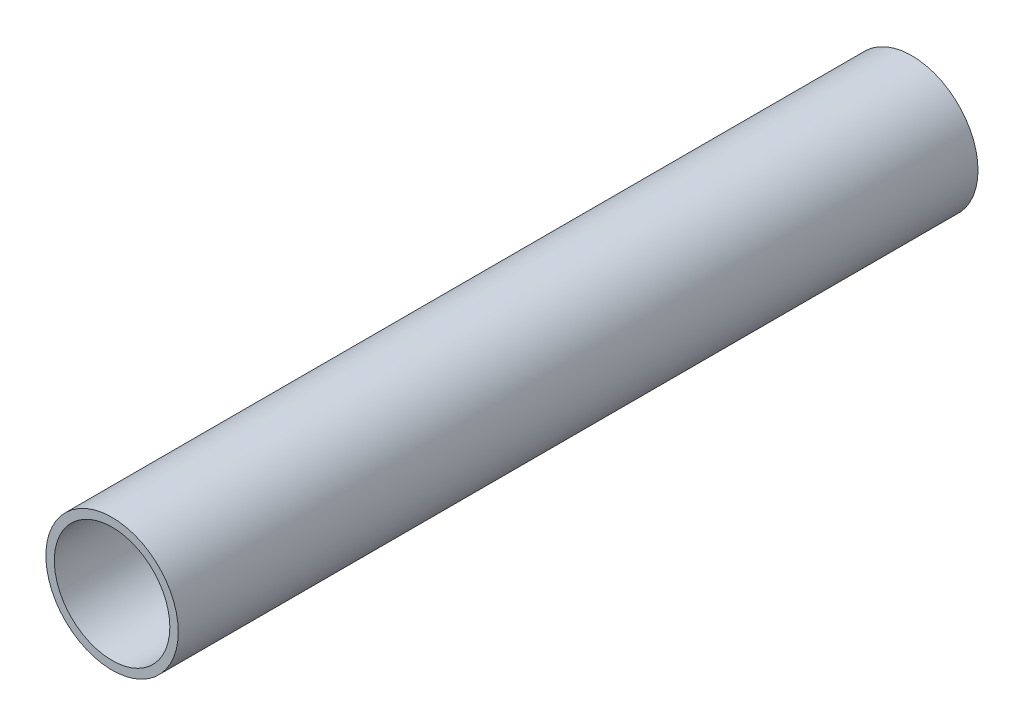
from build123d import *

# Parameters (mm, degrees)
SKETCH1_R           = 18.923
SKETCH1_R_2         = 16.51
BOSS_EXTRUDE1_DEPTH = 228.6


with BuildPart() as part:
    # Sketch1 → Boss-Extrude1 (new body)
    with BuildSketch(Plane.XY):
        Circle(SKETCH1_R)
        Circle(SKETCH1_R_2, mode=Mode.SUBTRACT)
    extrude(amount=BOSS_EXTRUDE1_DEPTH)


solid = part.part
